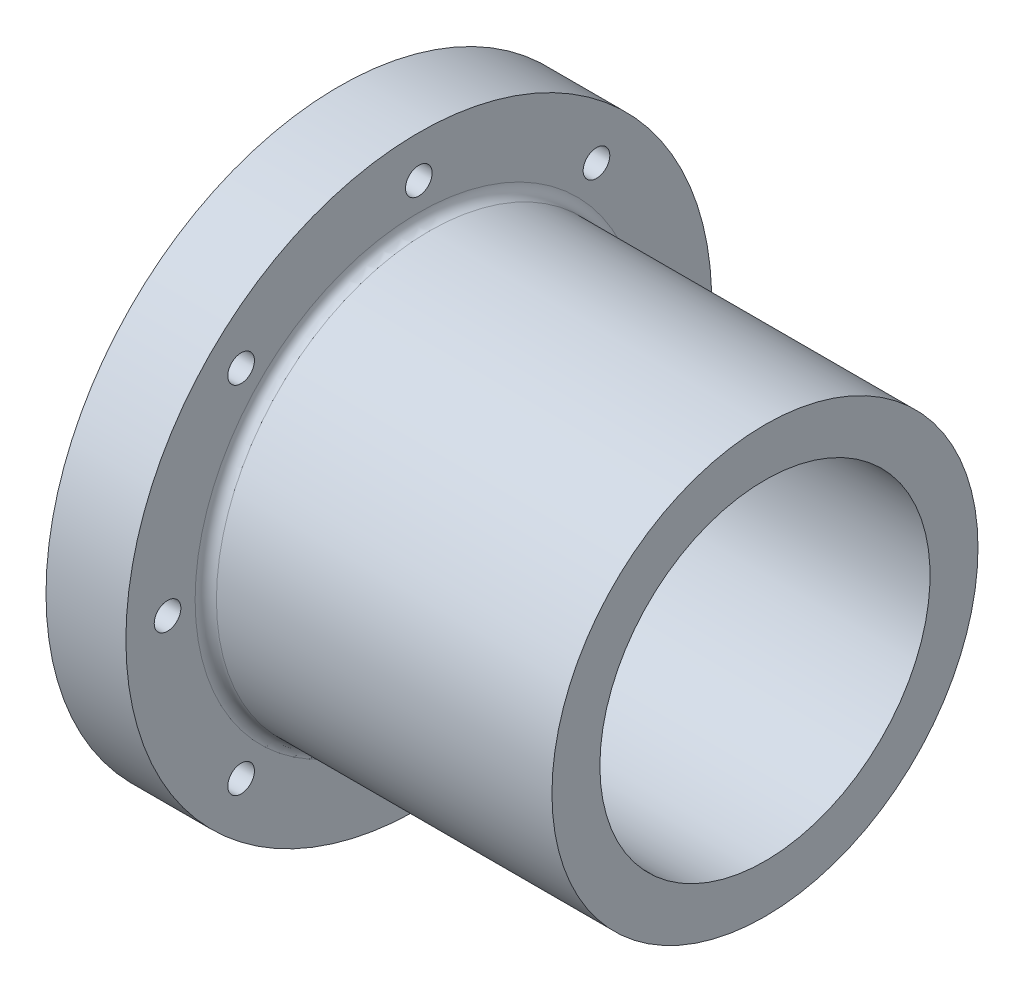
from build123d import *

# Parameters (mm, degrees)
CUT_EXTRUDE2_REACH                            = 103.6
SKETCH3_R                                     = 3.175
FILLET2_R                                     = 2.54
CBORE_FOR_8_SOCKET_HEAD_CAP_SCREW1_AT_2_COUNT = 2
CBORE_FOR_8_SOCKET_HEAD_CAP_SCREW1_AT_2_PITCH = 35.921024484
CBORE_FOR_8_SOCKET_HEAD_CAP_SCREW1_AT_3_COUNT = 2
CBORE_FOR_8_SOCKET_HEAD_CAP_SCREW1_AT_3_PITCH = 35.921024484
CBORE_FOR_8_SOCKET_HEAD_CAP_SCREW1_AT_4_COUNT = 2
CBORE_FOR_8_SOCKET_HEAD_CAP_SCREW1_AT_4_PITCH = 50.8
FILLET3_R                                     = 2.54
SKETCH8_R                                     = 50.8
CUT_EXTRUDE3_DEPTH                            = 3.175
FILLET4_R                                     = 1.27
F_3_16_0_1875_DIAMETER_HOLE1_D                = 4.7625
F_3_16_0_1875_DIAMETER_HOLE1_DEPTH            = 13.97
F_3_16_0_1875_DIAMETER_HOLE1_TIP              = 1.430799349
CHAMFER2_SIZE                                 = 1.27


with BuildPart() as part:
    # Sketch1 → Revolve1 (revolve)
    with BuildSketch(Plane.XY):
        Polygon((-30.109602918, 50.8), (-30.109602918, 39.37), (-13.599602918, 39.37), (-13.599602918, 11.43), (-0.899602918, 11.43), (-0.899602918, 39.37), (71.490397082, 39.37), (71.490397082, 50.8), (-11.059602918, 50.8), (-11.059602918, 69.85), (-30.109602918, 69.85), align=None)
    revolve(axis=Axis((0, 0, 0), (1, 0, 0)))

    # Sketch3 → Cut-Extrude2 (cut, up to next)
    with BuildSketch(Plane.ZY.offset(30.109602918), mode=Mode.PRIVATE) as cut_extrude2_sk1:
        with Locations((0, 59.9186)):
            Circle(SKETCH3_R)
    cut_extrude2_tool1 = extrude(cut_extrude2_sk1.sketch, amount=-CUT_EXTRUDE2_REACH, mode=Mode.PRIVATE) & part.part
    add(cut_extrude2_tool1.solids().sort_by_distance((-30.109603, 59.9186, 0))[0], mode=Mode.SUBTRACT)
    # Sketch3 → Cut-Extrude2 (cut, up to next)
    with BuildSketch(Plane.ZY.offset(30.109602918), mode=Mode.PRIVATE) as cut_extrude2_sk2:
        with Locations((42.368848379, 42.368848379)):
            Circle(SKETCH3_R)
    cut_extrude2_tool2 = extrude(cut_extrude2_sk2.sketch, amount=-CUT_EXTRUDE2_REACH, mode=Mode.PRIVATE) & part.part
    add(cut_extrude2_tool2.solids().sort_by_distance((-30.109603, 42.368848, 42.368848))[0], mode=Mode.SUBTRACT)
    # Sketch3 → Cut-Extrude2 (cut, up to next)
    with BuildSketch(Plane.ZY.offset(30.109602918), mode=Mode.PRIVATE) as cut_extrude2_sk3:
        with Locations((59.9186, 0)):
            Circle(SKETCH3_R)
    cut_extrude2_tool3 = extrude(cut_extrude2_sk3.sketch, amount=-CUT_EXTRUDE2_REACH, mode=Mode.PRIVATE) & part.part
    add(cut_extrude2_tool3.solids().sort_by_distance((-30.109603, 0, 59.9186))[0], mode=Mode.SUBTRACT)
    # Sketch3 → Cut-Extrude2 (cut, up to next)
    with BuildSketch(Plane.ZY.offset(30.109602918), mode=Mode.PRIVATE) as cut_extrude2_sk4:
        with Locations((42.368848379, -42.368848379)):
            Circle(SKETCH3_R)
    cut_extrude2_tool4 = extrude(cut_extrude2_sk4.sketch, amount=-CUT_EXTRUDE2_REACH, mode=Mode.PRIVATE) & part.part
    add(cut_extrude2_tool4.solids().sort_by_distance((-30.109603, -42.368848, 42.368848))[0], mode=Mode.SUBTRACT)
    # Sketch3 → Cut-Extrude2 (cut, up to next)
    with BuildSketch(Plane.ZY.offset(30.109602918), mode=Mode.PRIVATE) as cut_extrude2_sk5:
        with Locations((0, -59.9186)):
            Circle(SKETCH3_R)
    cut_extrude2_tool5 = extrude(cut_extrude2_sk5.sketch, amount=-CUT_EXTRUDE2_REACH, mode=Mode.PRIVATE) & part.part
    add(cut_extrude2_tool5.solids().sort_by_distance((-30.109603, -59.9186, 0))[0], mode=Mode.SUBTRACT)
    # Sketch3 → Cut-Extrude2 (cut, up to next)
    with BuildSketch(Plane.ZY.offset(30.109602918), mode=Mode.PRIVATE) as cut_extrude2_sk6:
        with Locations((-42.368848379, -42.368848379)):
            Circle(SKETCH3_R)
    cut_extrude2_tool6 = extrude(cut_extrude2_sk6.sketch, amount=-CUT_EXTRUDE2_REACH, mode=Mode.PRIVATE) & part.part
    add(cut_extrude2_tool6.solids().sort_by_distance((-30.109603, -42.368848, -42.368848))[0], mode=Mode.SUBTRACT)
    # Sketch3 → Cut-Extrude2 (cut, up to next)
    with BuildSketch(Plane.ZY.offset(30.109602918), mode=Mode.PRIVATE) as cut_extrude2_sk7:
        with Locations((-59.9186, 0)):
            Circle(SKETCH3_R)
    cut_extrude2_tool7 = extrude(cut_extrude2_sk7.sketch, amount=-CUT_EXTRUDE2_REACH, mode=Mode.PRIVATE) & part.part
    add(cut_extrude2_tool7.solids().sort_by_distance((-30.109603, 0, -59.9186))[0], mode=Mode.SUBTRACT)
    # Sketch3 → Cut-Extrude2 (cut, up to next)
    with BuildSketch(Plane.ZY.offset(30.109602918), mode=Mode.PRIVATE) as cut_extrude2_sk8:
        with Locations((-42.368848379, 42.368848379)):
            Circle(SKETCH3_R)
    cut_extrude2_tool8 = extrude(cut_extrude2_sk8.sketch, amount=-CUT_EXTRUDE2_REACH, mode=Mode.PRIVATE) & part.part
    add(cut_extrude2_tool8.solids().sort_by_distance((-30.109603, 42.368848, -42.368848))[0], mode=Mode.SUBTRACT)

    # Fillet2
    fillet2_edges = [part.edges().sort_by_distance(p)[0] for p in [
        (-0.899602918, -39.37, 0),
        (-13.599602918, -39.37, 0),
        (-11.059602918, -50.8, 0),
    ]]
    fillet(fillet2_edges, radius=FILLET2_R)

    # Sketch5 → CBORE for #8 Socket Head Cap Screw1 (revolve, cut)
    with BuildSketch(Plane(origin=(-13.599602918, -25.4, 0), x_dir=(0, 0, 1), z_dir=(0, 1, 0))):
        Polygon((0, 0), (0, 85.09), (2.2479, 85.09), (2.2479, 4.1656), (3.96875, 4.1656), (3.96875, 1.42875), (5.3975, 0), align=None)
    cbore_for_8_socket_head_cap_screw1 = revolve(axis=Axis((-19.949602918, -25.4, 0), (1, 0, 0)), mode=Mode.SUBTRACT)

    # CBORE for #8 Socket Head Cap Screw1 at 2: CBORE for #8 Socket Head Cap Screw1 ×2
    with Locations(*[Vector(0, 0.707106781, -0.707106781) * (i * CBORE_FOR_8_SOCKET_HEAD_CAP_SCREW1_AT_2_PITCH) for i in range(1, CBORE_FOR_8_SOCKET_HEAD_CAP_SCREW1_AT_2_COUNT)]):
        add(cbore_for_8_socket_head_cap_screw1, mode=Mode.SUBTRACT)

    # CBORE for #8 Socket Head Cap Screw1 at 3: CBORE for #8 Socket Head Cap Screw1 ×2
    with Locations(*[Vector(0, 0.707106781, 0.707106781) * (i * CBORE_FOR_8_SOCKET_HEAD_CAP_SCREW1_AT_3_PITCH) for i in range(1, CBORE_FOR_8_SOCKET_HEAD_CAP_SCREW1_AT_3_COUNT)]):
        add(cbore_for_8_socket_head_cap_screw1, mode=Mode.SUBTRACT)

    # CBORE for #8 Socket Head Cap Screw1 at 4: CBORE for #8 Socket Head Cap Screw1 ×2
    with Locations(*[(0, i * CBORE_FOR_8_SOCKET_HEAD_CAP_SCREW1_AT_4_PITCH, 0) for i in range(1, CBORE_FOR_8_SOCKET_HEAD_CAP_SCREW1_AT_4_COUNT)]):
        add(cbore_for_8_socket_head_cap_screw1, mode=Mode.SUBTRACT)

    # Fillet3
    fillet3_edges = [part.edges().sort_by_distance(p)[0] for p in [
        (-0.899602918, -11.43, 0),
        (-13.599602918, -11.43, 0),
    ]]
    fillet(fillet3_edges, radius=FILLET3_R)

    # Sketch8 → Cut-Extrude3 (cut)
    with BuildSketch(Plane.ZY.offset(30.109602918)):
        Circle(SKETCH8_R)
    extrude(amount=-CUT_EXTRUDE3_DEPTH, mode=Mode.SUBTRACT)

    # Fillet4
    fillet4_edges = [part.edges().sort_by_distance(p)[0] for p in [
        (-26.934602918, 0, -50.8),
    ]]
    fillet(fillet4_edges, radius=FILLET4_R)

    # 3/16 (0.1875) Diameter Hole1
    with Locations(Plane.ZY.offset(26.934602918)):
        with Locations((-44.45, 0), (0, 44.45), (44.45, 0), (0, -44.45)):
            Hole(F_3_16_0_1875_DIAMETER_HOLE1_D / 2, depth=F_3_16_0_1875_DIAMETER_HOLE1_DEPTH)
            with Locations((0, 0, -(F_3_16_0_1875_DIAMETER_HOLE1_DEPTH + F_3_16_0_1875_DIAMETER_HOLE1_TIP / 2))):  # 118° drill point
                Cone(0, F_3_16_0_1875_DIAMETER_HOLE1_D / 2, F_3_16_0_1875_DIAMETER_HOLE1_TIP, mode=Mode.SUBTRACT)

    # Chamfer2
    chamfer2_edges = [part.edges().sort_by_distance(p)[0] for p in [
        (-26.934602918, -39.37, 0),
    ]]
    chamfer(chamfer2_edges, length=CHAMFER2_SIZE)


solid = part.part
